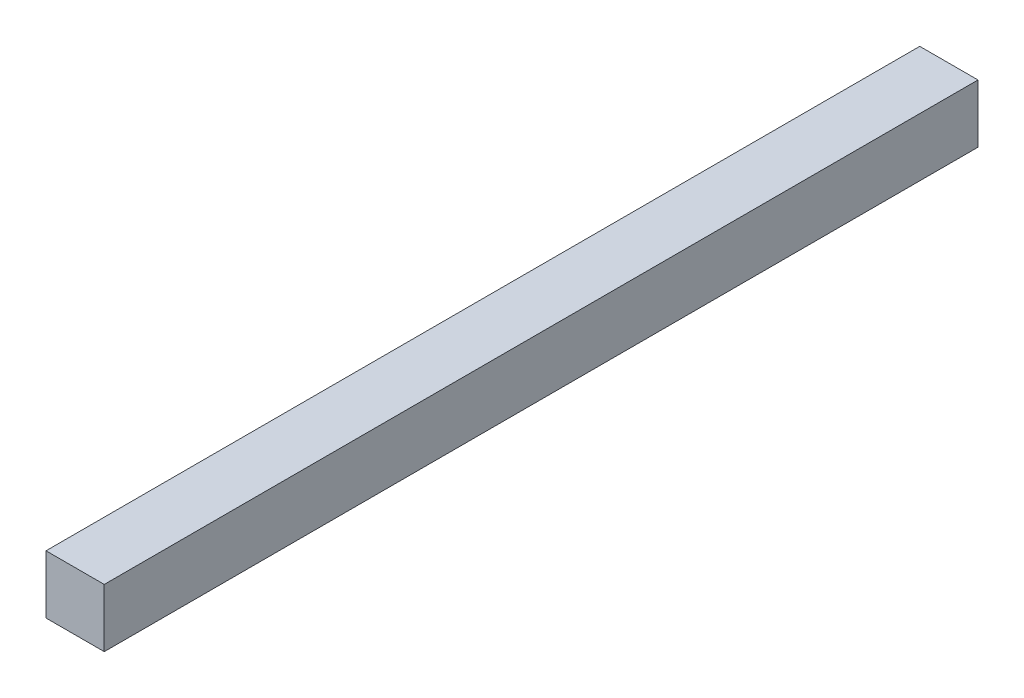
from build123d import *

# Parameters (mm, degrees)
SKETCH1_W           = 25.4
SKETCH1_H           = 25.4
BOSS_EXTRUDE1_DEPTH = 381


with BuildPart() as part:
    # Sketch1 → Boss-Extrude1 (new body)
    with BuildSketch(Plane.XY):
        Rectangle(SKETCH1_W, SKETCH1_H)
    extrude(amount=BOSS_EXTRUDE1_DEPTH)


solid = part.part
